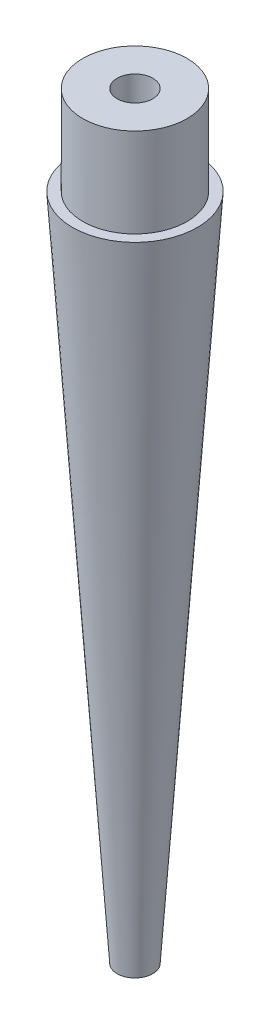
from build123d import *

# Parameters (mm, degrees)
SKETCH1_R               = 5.85
BOSS_EXTRUDE1_DEPTH     = 10
CUT_EXTRUDE1_DEPTH      = 106.465634213
CUT_EXTRUDE1_DEPTH_BACK = 106.465634213
SKETCH1_4_R             = 2


with BuildPart() as part:
    # Sketch2 → Revolve1 (revolve)
    with BuildSketch(Plane(origin=(0, 0, 0), x_dir=(0, 0, -1), z_dir=(1, 0, 0))):
        Polygon((0, -105), (7, 0), (0, 0), align=None)
    revolve(axis=Axis((0, 0, 0), (0, -1, 0)))

    # Sketch1 → Boss-Extrude1 (add)
    with BuildSketch(Plane(origin=(0, 0, 0), x_dir=(1, 0, 0), z_dir=(0, 1, 0))):
        Circle(SKETCH1_R)
    extrude(amount=BOSS_EXTRUDE1_DEPTH)

    # Sketch1_4 → Cut-Extrude1 (cut, two sides: drawn at the far end of the back side and taken through both)
    with BuildSketch(Plane(origin=(0, 0, 0), x_dir=(1, 0, 0), z_dir=(0, 1, 0)).offset(-CUT_EXTRUDE1_DEPTH_BACK)):
        Circle(SKETCH1_4_R)
    extrude(amount=CUT_EXTRUDE1_DEPTH + CUT_EXTRUDE1_DEPTH_BACK, mode=Mode.SUBTRACT)


solid = part.part
